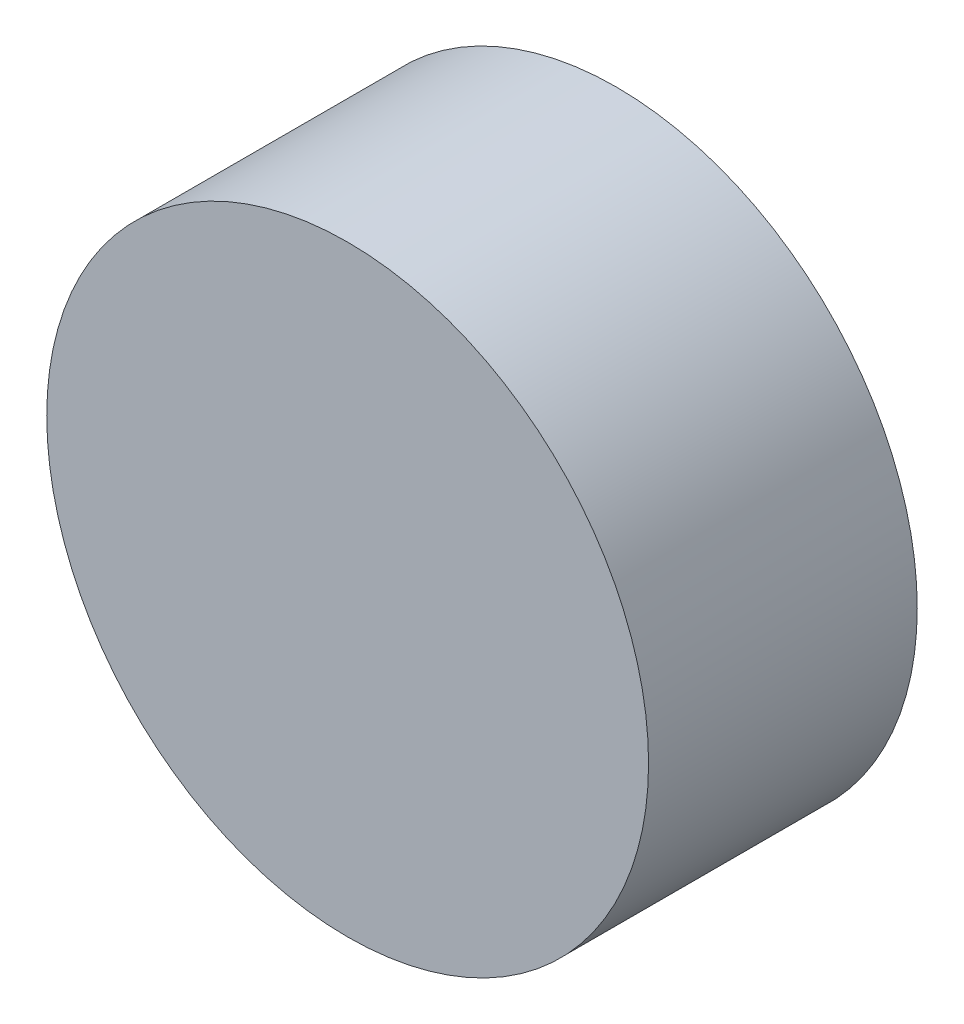
from build123d import *

# Parameters (mm, degrees)
SKETCH_1_R      = 5.6
EXTRUDE_1_DEPTH = 5


with BuildPart() as part:
    # 草圖1 → 填料-伸長1 (new body)
    with BuildSketch(Plane.XY):
        Circle(SKETCH_1_R)
    extrude(amount=EXTRUDE_1_DEPTH)


solid = part.part
